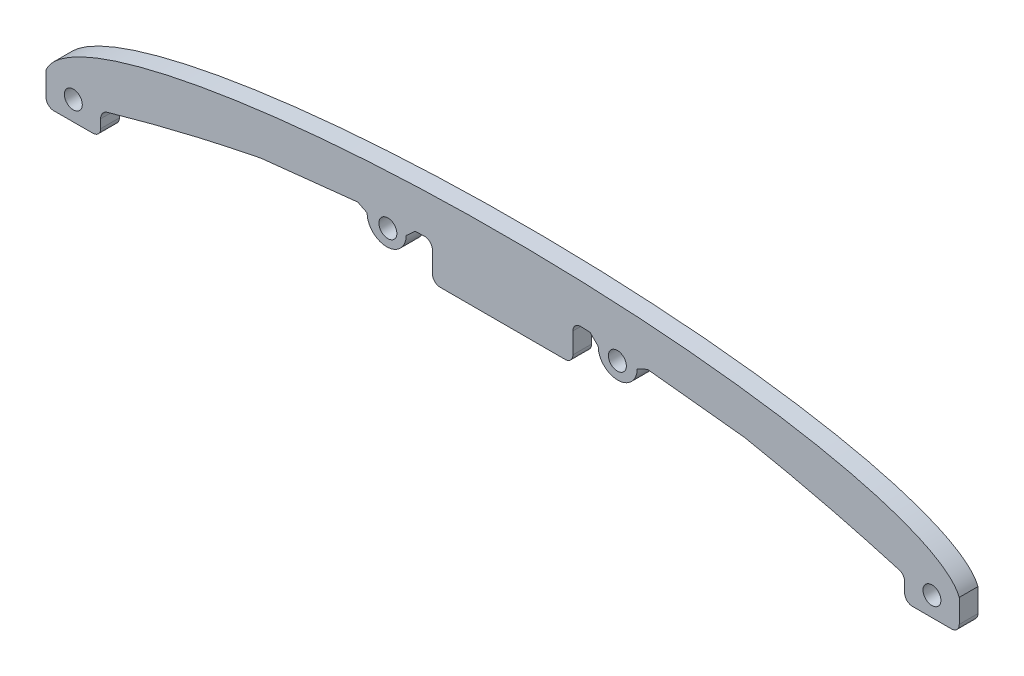
from build123d import *

# Parameters (mm, degrees)
BOSS_EXTRUDE2_DEPTH = 2.4
SKETCH1_R           = 1.15
CUT_EXTRUDE1_DEPTH  = 2.4


with BuildPart() as part:
    # Szkic1 → Boss-Extrude2 (new body)
    with BuildSketch(Plane.XY):
        with BuildLine():
            Line((-10.038681529, 6.811589572), (-11.201099301, 6.765821135))
            Line((-11.201099301, 6.765821135), (-12.356296421, 5.725087863))
            ThreePointArc((-12.356296421, 5.725087863), (-14.856296421, 3.225087863), (-17.356296421, 5.725087863))
            Line((-17.356296421, 5.725087863), (-18.554529735, 6.329270322))
            Line((-18.554529735, 6.329270322), (-31, 4.99130079))
            add(Edge.make_bspline(
                [(-31, 4.99130079), (-37.613672397, 3.688579862), (-44.160698718, 2.10757006), (-50.639420354, 0.248675937)],
                knots=[0, 0, 0, 0, 0.957580525, 0.957580525, 0.957580525, 0.957580525], degree=3))
            ThreePointArc((-50.639420354, 0.248675937), (-51.260787122, -0.178490214), (-51.500016351, -0.893568501))
            Line((-51.500016351, -0.893568501), (-51.500016351, -2.002159088))
            ThreePointArc((-51.500016351, -2.002159088), (-51.792145807, -2.708501281), (-52.497854937, -3.002156752))
            Line((-52.497854937, -3.002156752), (-57.497838586, -3.012963812))
            ThreePointArc((-57.497838586, -3.012963812), (-58.206342193, -2.720836692), (-58.5, -2.012966148))
            Line((-58.5, -2.012966148), (-58.5, 1.001731028))
            add(Edge.make_bspline(
                [(58.5, 1.001731028), (54.007233316, 12.041738456), (0, 12.041738456), (-54.007233316, 12.041738456), (-58.5, 1.001731028)],
                knots=[3.224877141, 3.224877141, 3.224877141, 4.71238898, 4.71238898, 6.199900819, 6.199900819, 6.199900819], degree=2, weights=[1, 0.735930785, 1, 0.735930785, 1]))
            Line((58.5, 1.001731028), (58.5, -1.998268938))
            ThreePointArc((58.5, -1.998268938), (58.207106781, -2.705375719), (57.5, -2.998268938))
            Line((57.5, -2.998268938), (52.5, -2.998268938))
            ThreePointArc((52.5, -2.998268938), (51.792893219, -2.705375719), (51.5, -1.998268938))
            Line((51.5, -1.998268938), (51.5, -0.746759199))
            ThreePointArc((51.5, -0.746759199), (51.30006128, -0.146840914), (50.780196103, 0.213183583))
            add(Edge.make_bspline(
                [(31, 4.99130079), (37.668939941, 3.708375899), (44.262338642, 2.115670164), (50.780196103, 0.213183583)],
                knots=[0, 0, 0, 0, 0.964480492, 0.964480492, 0.964480492, 0.964480492], degree=3))
            Line((31, 4.99130079), (18.55432572, 6.329285731))
            Line((18.55432572, 6.329285731), (17.243703579, 5.725087863))
            ThreePointArc((17.243703579, 5.725087863), (14.743703579, 3.225087863), (12.243703579, 5.725087863))
            Line((12.243703579, 5.725087863), (11.202144167, 6.765775333))
            Line((11.202144167, 6.765775333), (10.039906762, 6.81154198))
            ThreePointArc((10.039906762, 6.81154198), (9.307503491, 6.533200421), (9.000559204, 5.812316395))
            Line((9.000559204, 5.812316395), (9.000559204, 3.152512128))
            ThreePointArc((9.000559204, 3.152512128), (8.707665985, 2.445405346), (8.000559204, 2.152512128))
            Line((8.000559204, 2.152512128), (-7.999338529, 2.152512128))
            ThreePointArc((-7.999338529, 2.152512128), (-8.70644531, 2.445405346), (-8.999338529, 3.152512128))
            Line((-8.999338529, 3.152512128), (-8.999338529, 5.812363808))
            ThreePointArc((-8.999338529, 5.812363808), (-9.306281172, 6.533246253), (-10.038681529, 6.811589572))
        make_face()
    extrude(amount=BOSS_EXTRUDE2_DEPTH)

    # Sketch1 → Cut-Extrude1 (cut)
    with BuildSketch(Plane.XY.offset(2.4)):
        with Locations((-55, -0.507559097)):
            Circle(SKETCH1_R)
        with Locations((-14.699338529, 5.352512128)):
            Circle(SKETCH1_R)
        with Locations((14.700559204, 5.352512128)):
            Circle(SKETCH1_R)
        with Locations((55, -0.507559097)):
            Circle(SKETCH1_R)
    extrude(amount=-CUT_EXTRUDE1_DEPTH, mode=Mode.SUBTRACT)


solid = part.part
